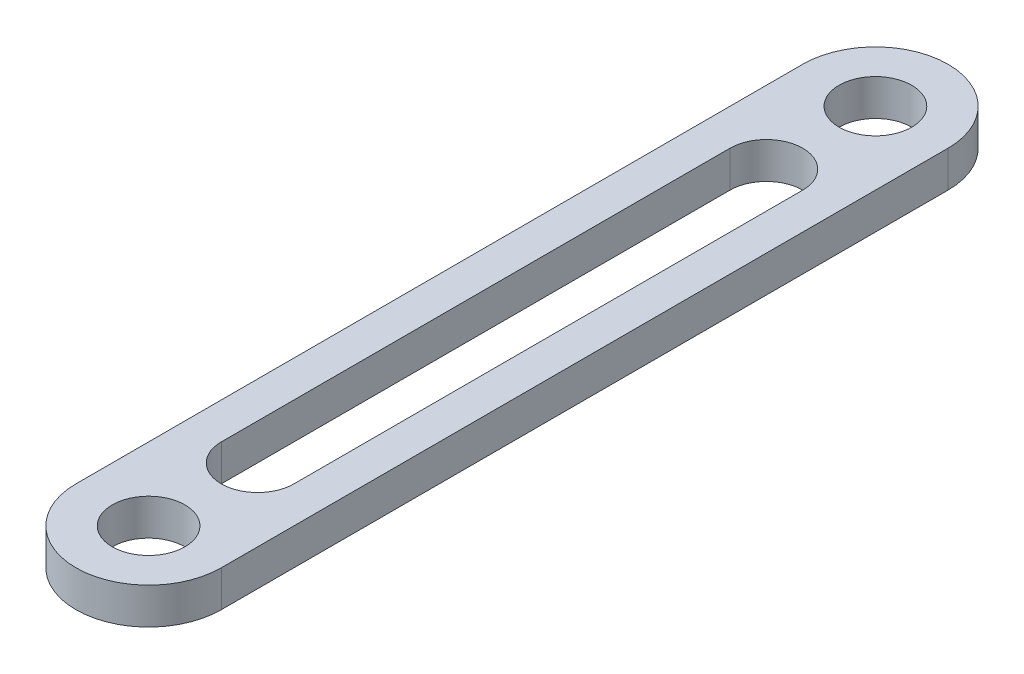
from build123d import *

# Parameters (mm, degrees)
SKETCH2_R           = 5
BOSS_EXTRUDE1_DEPTH = 5


with BuildPart() as part:
    # Sketch2 → Boss-Extrude1 (new body)
    with BuildSketch(Plane(origin=(0, 0, 0), x_dir=(1, 0, 0), z_dir=(0, 1, 0))):
        with BuildLine():
            Line((10, 0), (10, -100))
            ThreePointArc((10, -100), (0, -110), (-10, -100))
            Line((-10, -100), (-10, 0))
            ThreePointArc((-10, 0), (0, 10), (10, 0))
        make_face()
        Circle(SKETCH2_R, mode=Mode.SUBTRACT)
        with Locations((0, -100)):
            Circle(SKETCH2_R, mode=Mode.SUBTRACT)
        with BuildLine():
            Line((5, -15), (5, -85))
            ThreePointArc((5, -85), (0, -90), (-5, -85))
            Line((-5, -85), (-5, -15))
            ThreePointArc((-5, -15), (0, -10), (5, -15))
        make_face(mode=Mode.SUBTRACT)
    extrude(amount=BOSS_EXTRUDE1_DEPTH)


solid = part.part
